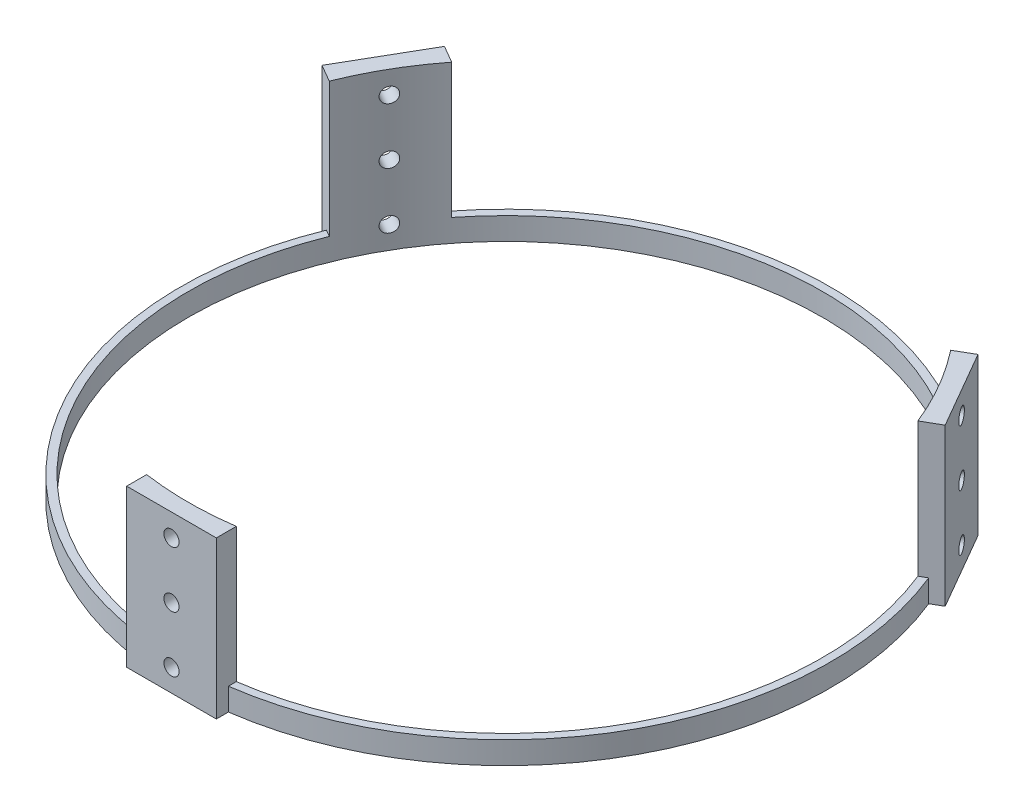
from build123d import *

# Parameters (mm, degrees)
SKETCH1_R               = 92.075
BOSS_EXTRUDE1_DEPTH     = 6.35
BOSS_EXTRUDE4_START     = 94.615
SKETCH2_W               = 25.4
SKETCH2_H               = 44.45
BOSS_EXTRUDE4_DEPTH     = 6.35
SKETCH4_R               = 2.1463
CUT_EXTRUDE2_DEPTH      = 6.35
CIRPATTERN1_COUNT       = 3
SKETCH3_R               = 89.8525
CUT_EXTRUDE1_DEPTH      = 50.8
CUT_EXTRUDE1_DEPTH_BACK = 6.35


with BuildPart() as part:
    # Sketch1 → Boss-Extrude1 (new body)
    with BuildSketch(Plane(origin=(0, 0, 0), x_dir=(1, 0, 0), z_dir=(0, 1, 0))):
        Circle(SKETCH1_R)
    extrude(amount=BOSS_EXTRUDE1_DEPTH)

    # Sketch2 → Boss-Extrude4 (add)
    with BuildSketch(Plane.XY.offset(BOSS_EXTRUDE4_START)):
        with Locations((0, 22.225)):
            Rectangle(SKETCH2_W, SKETCH2_H)
    boss_extrude4 = extrude(amount=-BOSS_EXTRUDE4_DEPTH)

    # Sketch4 → Cut-Extrude2 (cut)
    with BuildSketch(Plane.XY.offset(94.615)):
        with Locations((0, 38.1)):
            Circle(SKETCH4_R)
        with Locations((0, 22.225)):
            Circle(SKETCH4_R)
        with Locations((0, 6.35)):
            Circle(SKETCH4_R)
    cut_extrude2 = extrude(amount=-CUT_EXTRUDE2_DEPTH, mode=Mode.SUBTRACT)

    # CirPattern1: Boss-Extrude4, Cut-Extrude2 ×3 about axis
    cirpattern1_axis = Axis((0, 0, 0), (0, 1, 0))
    for i in range(1, CIRPATTERN1_COUNT):
        add(boss_extrude4.rotate(cirpattern1_axis, i * 360 / CIRPATTERN1_COUNT))
        add(cut_extrude2.rotate(cirpattern1_axis, i * 360 / CIRPATTERN1_COUNT), mode=Mode.SUBTRACT)

    # Sketch3 → Cut-Extrude1 (cut, two sides)
    with BuildSketch(Plane(origin=(0, 6.35, 0), x_dir=(1, 0, 0), z_dir=(0, 1, 0))) as cut_extrude1_sk:
        Circle(SKETCH3_R)
    extrude(amount=CUT_EXTRUDE1_DEPTH, mode=Mode.SUBTRACT)
    extrude(cut_extrude1_sk.sketch, amount=-CUT_EXTRUDE1_DEPTH_BACK, mode=Mode.SUBTRACT)


solid = part.part
